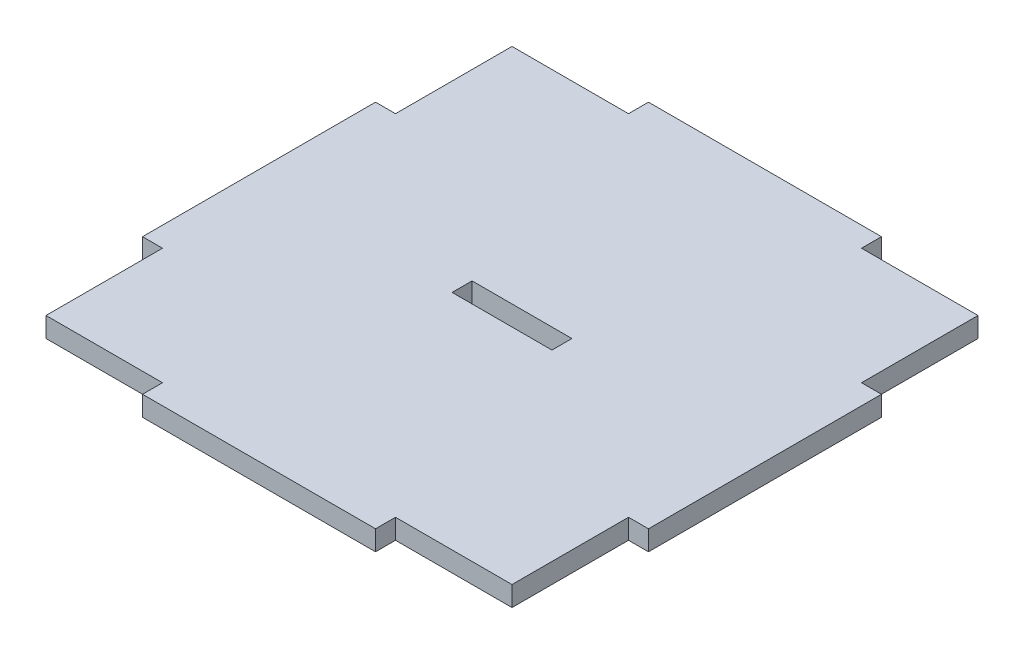
from build123d import *

# Parameters (mm, degrees)
BOSS_EXTRUDE1_DEPTH = 3
SKETCH2_W           = 15
SKETCH2_H           = 3
CUT_EXTRUDE1_DEPTH  = 3


with BuildPart() as part:
    # Sketch1 → Boss-Extrude1 (new body)
    with BuildSketch(Plane(origin=(0, 0, 0), x_dir=(1, 0, 0), z_dir=(0, 1, 0))):
        Polygon((-35, -35), (-17.5, -35), (-17.5, -38), (17.5, -38), (17.5, -35), (35, -35), (35, -17.5), (38, -17.5), (38, 17.5), (35, 17.5), (35, 35), (17.5, 35), (17.5, 38), (-17.5, 38), (-17.5, 35), (-35, 35), (-35, 17.5), (-38, 17.5), (-38, -17.5), (-35, -17.5), align=None)
    extrude(amount=BOSS_EXTRUDE1_DEPTH)

    # Sketch2 → Cut-Extrude1 (cut)
    with BuildSketch(Plane(origin=(0, 3, 0), x_dir=(1, 0, 0), z_dir=(0, 1, 0))):
        Rectangle(SKETCH2_W, SKETCH2_H)
    extrude(amount=-CUT_EXTRUDE1_DEPTH, mode=Mode.SUBTRACT)


solid = part.part
